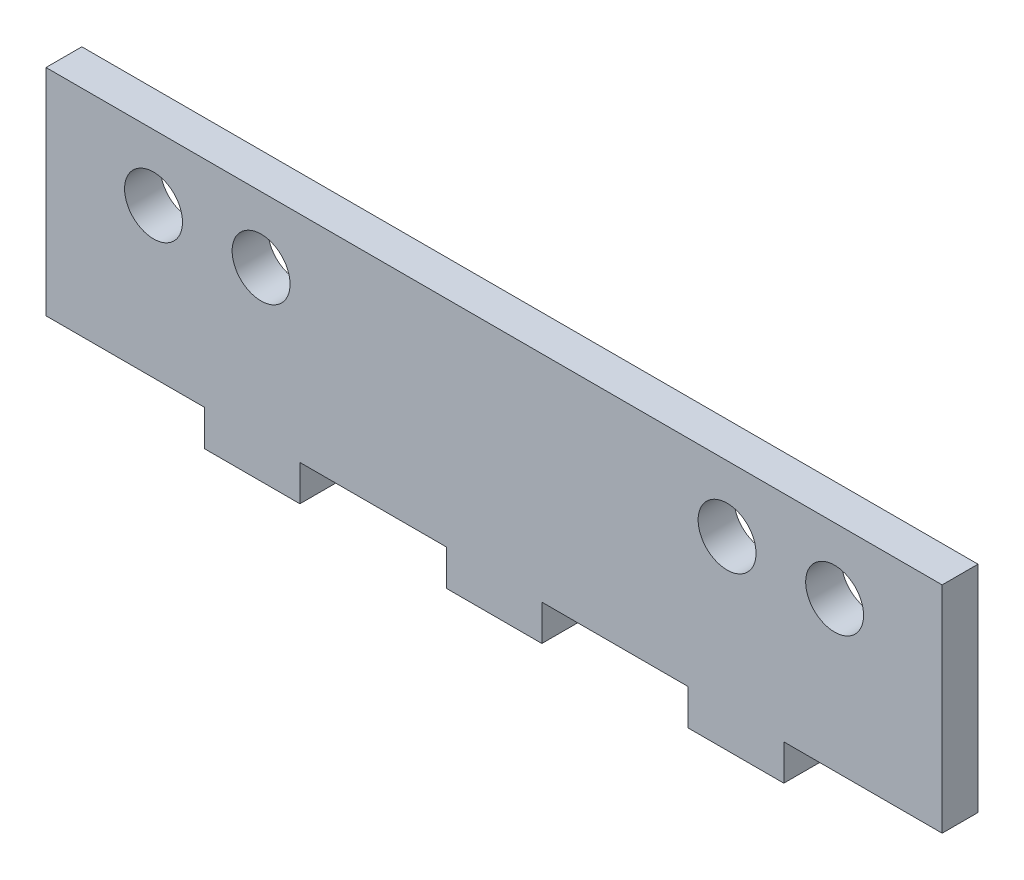
from build123d import *

# Parameters (mm, degrees)
SKETCH1_W           = 75
SKETCH1_H           = 18
BOSS_EXTRUDE1_DEPTH = 3
SKETCH2_W           = 8
SKETCH2_H           = 3
BOSS_EXTRUDE2_DEPTH = 3
SKETCH3_R           = 2.425
CUT_EXTRUDE1_DEPTH  = 3


with BuildPart() as part:
    # Sketch1 → Boss-Extrude1 (new body)
    with BuildSketch(Plane.XY):
        Rectangle(SKETCH1_W, SKETCH1_H)
    extrude(amount=BOSS_EXTRUDE1_DEPTH)

    # Sketch2 → Boss-Extrude2 (add)
    with BuildSketch(Plane(origin=(0, -9, 0), x_dir=(-1, 0, 0), z_dir=(0, -1, 0))):
        with Locations((-20.25, -1.5)):
            Rectangle(SKETCH2_W, SKETCH2_H)
        with Locations((0, -1.5)):
            Rectangle(SKETCH2_W, SKETCH2_H)
        with Locations((20.25, -1.5)):
            Rectangle(SKETCH2_W, SKETCH2_H)
    extrude(amount=BOSS_EXTRUDE2_DEPTH)

    # Sketch3 → Cut-Extrude1 (cut)
    with BuildSketch(Plane(origin=(0, 0, 0), x_dir=(-1, 0, 0), z_dir=(0, 0, -1))):
        with Locations((-28.5, 3.5)):
            Circle(SKETCH3_R)
        with Locations((28.5, 3.5)):
            Circle(SKETCH3_R)
        with Locations((-19.5, 3.5)):
            Circle(SKETCH3_R)
        with Locations((19.5, 3.5)):
            Circle(SKETCH3_R)
    extrude(amount=-CUT_EXTRUDE1_DEPTH, mode=Mode.SUBTRACT)


solid = part.part
